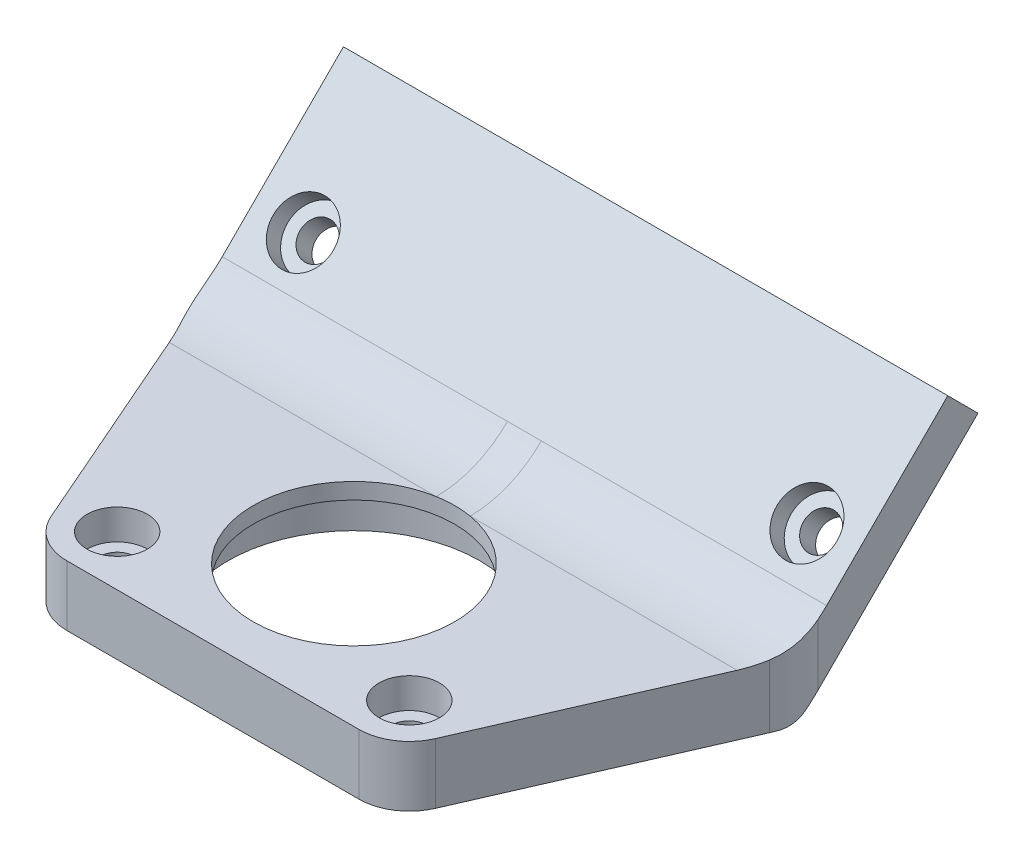
from build123d import *

# Parameters (mm, degrees)
SALIENTE_EXTRUIR1_DEPTH      = 30
SALIENTE_EXTRUIR1_DEPTH_BACK = 30
CROQUIS3_R                   = 1.75
CORTAR_EXTRUIR1_DEPTH        = 4.242641
CROQUIS4_R                   = 3
CORTAR_EXTRUIR2_DEPTH        = 2
CROQUIS5_R                   = 10
CROQUIS5_R_2                 = 1.75
CORTAR_EXTRUIR3_DEPTH        = 6
CROQUIS5_4_R                 = 12.5
CROQUIS5_4_R_2               = 10
CORTAR_EXTRUIR4_DEPTH        = 4.4
REDONDEO1_R                  = 10
REDONDEO2_R                  = 3
REDONDEO3_R                  = 10
CROQUIS6_R                   = 3
CORTAR_EXTRUIR5_DEPTH        = 3


with BuildPart() as part:
    # Croquis2 → Saliente-Extruir1 (new body, two sides)
    with BuildSketch(Plane(origin=(0, 0, 0), x_dir=(0, 0, -1), z_dir=(1, 0, 0))) as saliente_extruir1_sk:
        Polygon((0, 0), (-28, 0), (-28, 6), (0, 6), (14.960512242, 20.960512242), (17.960512242, 17.960512242), align=None)
    extrude(amount=SALIENTE_EXTRUIR1_DEPTH)
    extrude(saliente_extruir1_sk.sketch, amount=-SALIENTE_EXTRUIR1_DEPTH_BACK)

    # Croquis3 → Cortar-Extruir1 (cut)
    with BuildSketch(Plane(origin=(0, 0, 0), x_dir=(-1, 0, 0), z_dir=(0, -0.707106781, -0.707106781))):
        with Locations((-25, 12.7)):
            Circle(CROQUIS3_R)
        with Locations((25, 12.7)):
            Circle(CROQUIS3_R)
    extrude(amount=-CORTAR_EXTRUIR1_DEPTH, mode=Mode.SUBTRACT)

    # Croquis4 → Cortar-Extruir2 (cut)
    with BuildSketch(Plane(origin=(0, 3, 3), x_dir=(1, 0, 0), z_dir=(0, 0.707106781, 0.707106781))):
        with Locations((-25, 12.7)):
            Circle(CROQUIS4_R)
        with Locations((25, 12.7)):
            Circle(CROQUIS4_R)
    extrude(amount=-CORTAR_EXTRUIR2_DEPTH, mode=Mode.SUBTRACT)

    # Croquis5 → Cortar-Extruir3 (cut)
    with BuildSketch(Plane(origin=(0, 0, 0), x_dir=(-1, 0, 0), z_dir=(0, -1, 0))):
        with Locations((0, -14)):
            Circle(CROQUIS5_R)
        with Locations((14.5, -23)):
            Circle(CROQUIS5_R_2)
        with Locations((-14.5, -23)):
            Circle(CROQUIS5_R_2)
        with BuildLine():
            ThreePointArc((-19.082136833, -25.001005257), (-17.238153914, -27.1836005), (-14.5, -28))
            Line((-14.5, -28), (-30, -28))
            Line((-30, -28), (-30, 0))
            Line((-30, 0), (-19.082136833, -25.001005257))
        make_face()
        with BuildLine():
            Line((30, 0), (19.082136833, -25.001005257))
            ThreePointArc((19.082136833, -25.001005257), (17.238153914, -27.1836005), (14.5, -28))
            Line((14.5, -28), (30, -28))
            Line((30, -28), (30, 0))
        make_face()
    extrude(amount=-CORTAR_EXTRUIR3_DEPTH, mode=Mode.SUBTRACT)

    # Croquis5_4 → Cortar-Extruir4 (cut)
    with BuildSketch(Plane(origin=(0, 0, 0), x_dir=(-1, 0, 0), z_dir=(0, -1, 0))):
        with Locations((0, -14)):
            Circle(CROQUIS5_4_R)
        with Locations((0, -14)):
            Circle(CROQUIS5_4_R_2, mode=Mode.SUBTRACT)
    extrude(amount=-CORTAR_EXTRUIR4_DEPTH, mode=Mode.SUBTRACT)

    # Redondeo1
    redondeo1_edges = [part.edges().sort_by_distance(p)[0] for p in [
        (0, 6, 0),
    ]]
    fillet(redondeo1_edges, radius=REDONDEO1_R)

    # Redondeo2
    redondeo2_edges = [part.edges().sort_by_distance(p)[0] for p in [
        (0, 0, 0),
    ]]
    fillet(redondeo2_edges, radius=REDONDEO2_R)

    # Redondeo3
    redondeo3_edges = [part.edges().sort_by_distance(p)[0] for p in [
        (-30, 3.583831813, 0),
        (30, 3.583831813, 0),
    ]]
    fillet(redondeo3_edges, radius=REDONDEO3_R)

    # Croquis6 → Cortar-Extruir5 (cut)
    with BuildSketch(Plane(origin=(0, 6, 0), x_dir=(1, 0, 0), z_dir=(0, 1, 0))):
        with Locations((14.5, -23)):
            Circle(CROQUIS6_R)
        with Locations((-14.5, -23)):
            Circle(CROQUIS6_R)
    extrude(amount=-CORTAR_EXTRUIR5_DEPTH, mode=Mode.SUBTRACT)


solid = part.part
